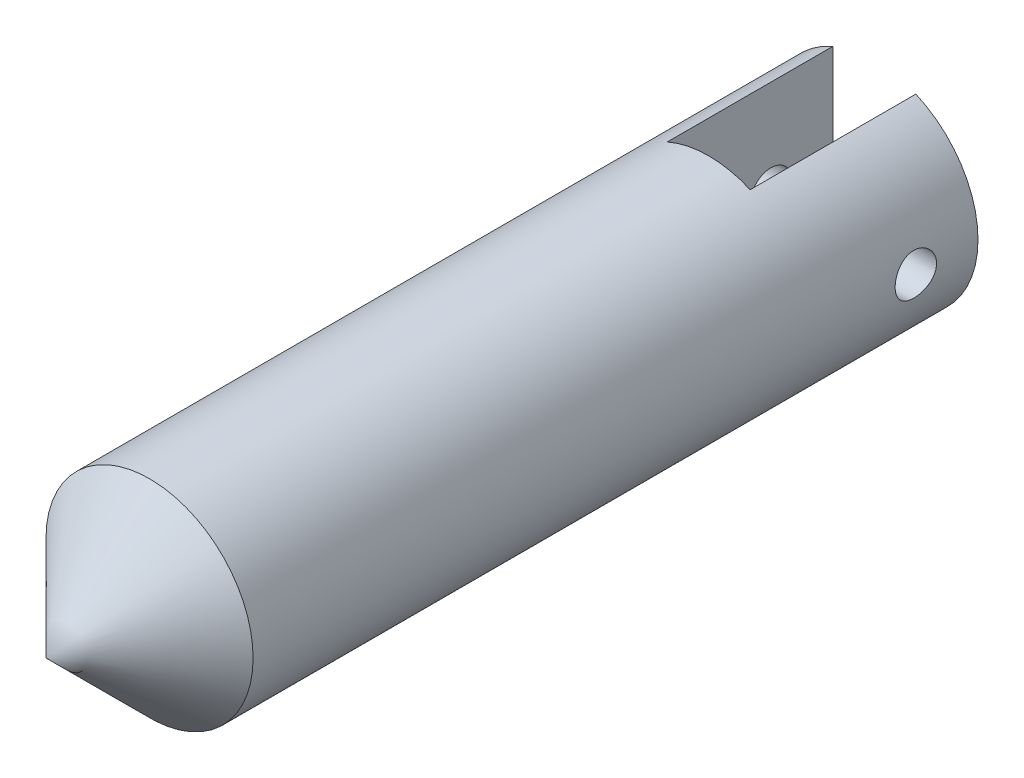
from build123d import *

# Parameters (mm, degrees)
SKETCH2_R               = 6.35
BOSS_EXTRUDE1_DEPTH     = 44.45
SKETCH4_W               = 5.08
SKETCH4_H               = 12.7
CUT_EXTRUDE1_DEPTH      = 10.16
SKETCH5_R               = 1.27
CUT_EXTRUDE2_DEPTH      = 9.89
CUT_EXTRUDE2_DEPTH_BACK = 4.81


with BuildPart() as part:
    # Sketch2 → Boss-Extrude1 (new body)
    with BuildSketch(Plane.XY):
        Circle(SKETCH2_R)
    extrude(amount=BOSS_EXTRUDE1_DEPTH)

    # Sketch3 → Revolve1 (revolve)
    with BuildSketch(Plane(origin=(0, 0, 0), x_dir=(0, 0, -1), z_dir=(1, 0, 0))):
        Polygon((-50.8, 0), (-44.45, 6.35), (-44.45, 0), align=None)
    revolve(axis=Axis((0, 0, 50.8), (0, 0, -1)))

    # Sketch4 → Cut-Extrude1 (cut)
    with BuildSketch(Plane(origin=(0, 0, 0), x_dir=(-1, 0, 0), z_dir=(0, 0, -1))):
        Rectangle(SKETCH4_W, SKETCH4_H)
    extrude(amount=-CUT_EXTRUDE1_DEPTH, mode=Mode.SUBTRACT)

    # Sketch5 → Cut-Extrude2 (cut, two sides)
    with BuildSketch(Plane.ZY.offset(-2.54)) as cut_extrude2_sk:
        with Locations((3.81, 0)):
            Circle(SKETCH5_R)
    extrude(amount=CUT_EXTRUDE2_DEPTH, mode=Mode.SUBTRACT)
    extrude(cut_extrude2_sk.sketch, amount=-CUT_EXTRUDE2_DEPTH_BACK, mode=Mode.SUBTRACT)


solid = part.part
